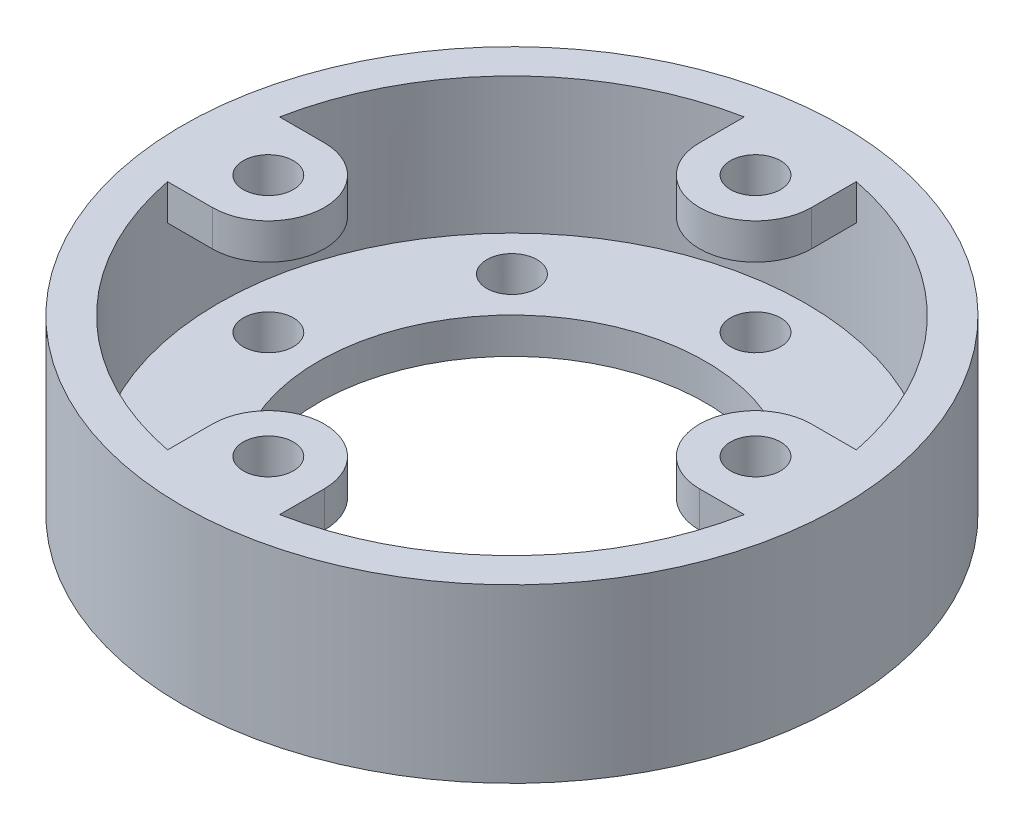
from build123d import *

# Parameters (mm, degrees)
SKETCH1_R          = 73.025
SKETCH1_R_2        = 42.8625
EXTRUDE1_DEPTH     = 38.1
SKETCH2_R          = 65.0875
CUT_EXTRUDE1_DEPTH = 30.1625
SKETCH3_R          = 5.55625
CUT_EXTRUDE2_DEPTH = 30.1625
CIRPATTERN1_COUNT  = 8
SKETCH5_R          = 5.55625
EXTRUDE2_DEPTH     = 7.9375
CIRPATTERN2_COUNT  = 4


with BuildPart() as part:
    # Sketch1 → Extrude1 (new body)
    with BuildSketch(Plane(origin=(0, 0, 0), x_dir=(1, 0, 0), z_dir=(0, 1, 0))):
        Circle(SKETCH1_R)
        Circle(SKETCH1_R_2, mode=Mode.SUBTRACT)
    extrude(amount=EXTRUDE1_DEPTH)

    # Sketch2 → Cut-Extrude1 (cut)
    with BuildSketch(Plane(origin=(0, 38.1, 0), x_dir=(-1, 0, 0), z_dir=(0, 1, 0))):
        Circle(SKETCH2_R)
    extrude(amount=-CUT_EXTRUDE1_DEPTH, mode=Mode.SUBTRACT)

    # Sketch3 → Cut-Extrude2 (cut)
    with BuildSketch(Plane(origin=(0, 7.9375, 0), x_dir=(-1, 0, 0), z_dir=(0, 1, 0))):
        with Locations((0, -53.975)):
            Circle(SKETCH3_R)
    cut_extrude2 = extrude(amount=-CUT_EXTRUDE2_DEPTH, mode=Mode.SUBTRACT)

    # CirPattern1: Cut-Extrude2 ×8 about axis
    cirpattern1_axis = Axis((0, 0, 0), (0, 1, 0))
    for i in range(1, CIRPATTERN1_COUNT):
        add(cut_extrude2.rotate(cirpattern1_axis, i * 360 / CIRPATTERN1_COUNT), mode=Mode.SUBTRACT)

    # Sketch5 → Extrude2 (add)
    with BuildSketch(Plane(origin=(0, 38.1, 0), x_dir=(-1, 0, 0), z_dir=(0, 1, 0))):
        with BuildLine():
            ThreePointArc((-12.413038972, -63.892872214), (0, -65.0875), (12.413038972, -63.892872214))
            Line((12.413038972, -63.892872214), (12.413038972, -53.975))
            ThreePointArc((12.413038972, -53.975), (0, -41.561961028), (-12.413038972, -53.975))
            Line((-12.413038972, -53.975), (-12.413038972, -63.892872214))
        make_face()
        with Locations((0, -53.975)):
            Circle(SKETCH5_R, mode=Mode.SUBTRACT)
    extrude2 = extrude(amount=-EXTRUDE2_DEPTH)

    # CirPattern2: Extrude2 ×4 about axis
    cirpattern2_axis = Axis((0, 0, 0), (0, 1, 0))
    for i in range(1, CIRPATTERN2_COUNT):
        add(extrude2.rotate(cirpattern2_axis, i * 360 / CIRPATTERN2_COUNT))


solid = part.part
